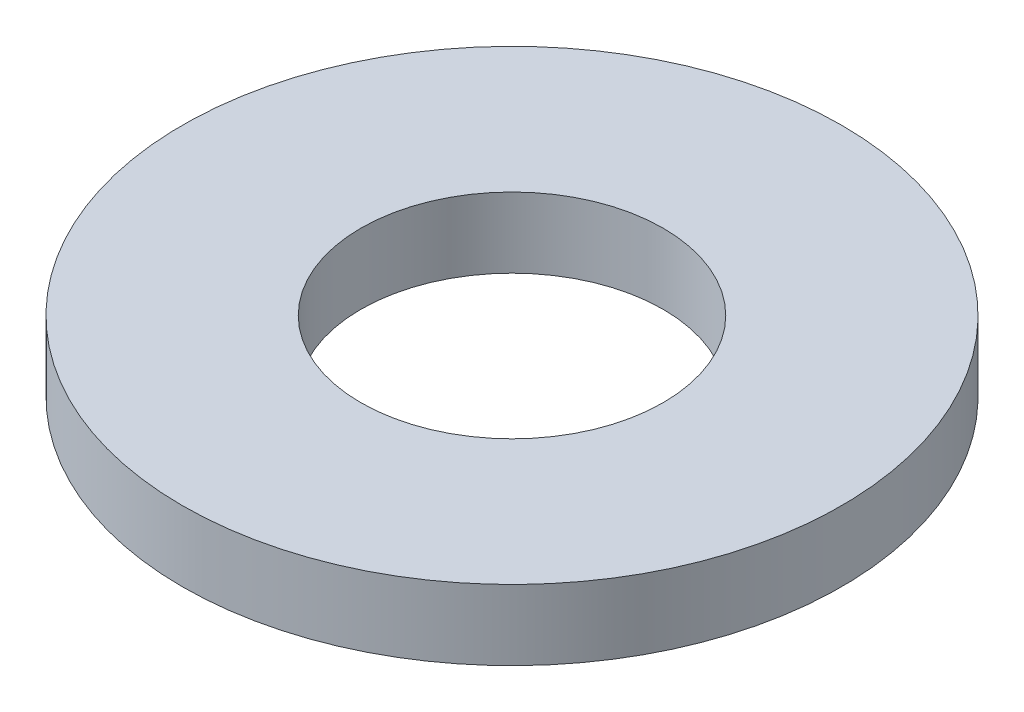
from build123d import *

# Parameters (mm, degrees)
SKETCH1_R           = 4.7625
BOSS_EXTRUDE1_DEPTH = 1.016
SKETCH5_R           = 2.1844
CUT_EXTRUDE1_DEPTH  = 2.016


with BuildPart() as part:
    # Sketch1 → Boss-Extrude1 (new body)
    with BuildSketch(Plane(origin=(0, 0, 0), x_dir=(1, 0, 0), z_dir=(0, 1, 0))):
        Circle(SKETCH1_R)
    extrude(amount=BOSS_EXTRUDE1_DEPTH)

    # Sketch5 → Cut-Extrude1 (cut, through all)
    with BuildSketch(Plane(origin=(0, 1.016, 0), x_dir=(-1, 0, 0), z_dir=(0, 1, 0))):
        Circle(SKETCH5_R)
    extrude(amount=-CUT_EXTRUDE1_DEPTH, mode=Mode.SUBTRACT)


solid = part.part
